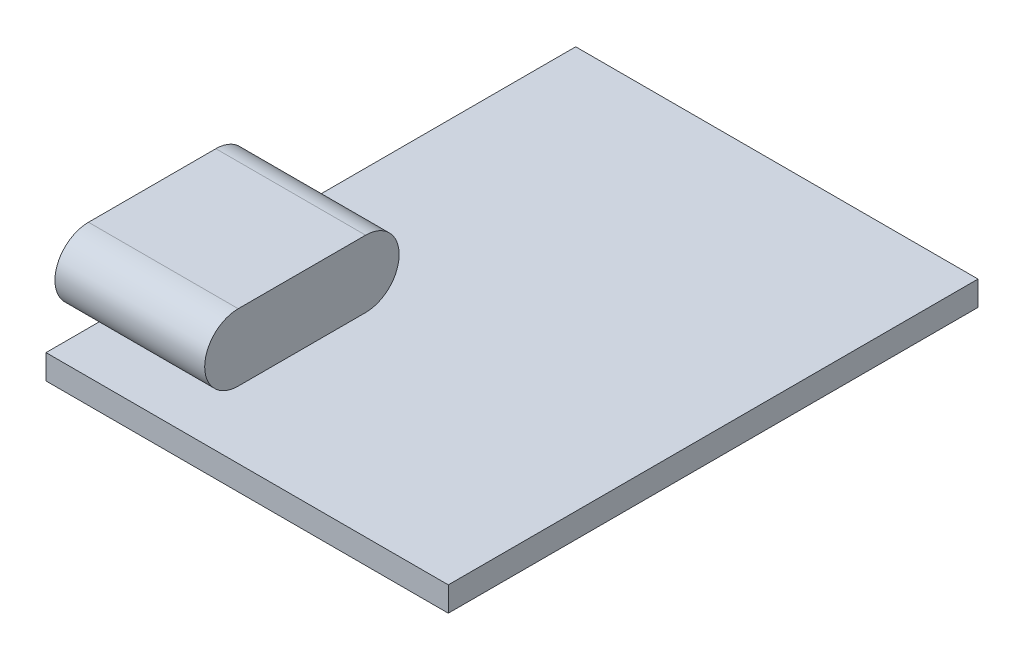
from build123d import *

# Parameters (mm, degrees)
ESBO_O1_W                     = 18
ESBO_O1_H                     = 23.7
RESSALTO_EXTRUS_O1_DEPTH      = 1.1
RESSALTO_EXTRUS_O2_DEPTH      = 1.1
RESSALTO_EXTRUS_O2_DEPTH_BACK = 5.6


with BuildPart() as part:
    # Esboço1 → Ressalto-extrusão1 (new body)
    with BuildSketch(Plane(origin=(0, 0, 0), x_dir=(1, 0, 0), z_dir=(0, 1, 0))):
        with Locations((9, 11.85)):
            Rectangle(ESBO_O1_W, ESBO_O1_H)
    extrude(amount=RESSALTO_EXTRUS_O1_DEPTH)

    # Esboço2 → Ressalto-extrusão2 (add, two sides)
    with BuildSketch(Plane.ZY) as ressalto_extrus_o2_sk:
        with BuildLine():
            Line((-8.7, 4.1), (-3, 4.1))
            ThreePointArc((-3, 4.1), (-1.5, 2.6), (-3, 1.1))
            Line((-3, 1.1), (-8.7, 1.1))
            ThreePointArc((-8.7, 1.1), (-10.2, 2.6), (-8.7, 4.1))
        make_face()
    extrude(amount=RESSALTO_EXTRUS_O2_DEPTH)
    extrude(ressalto_extrus_o2_sk.sketch, amount=-RESSALTO_EXTRUS_O2_DEPTH_BACK)


solid = part.part
